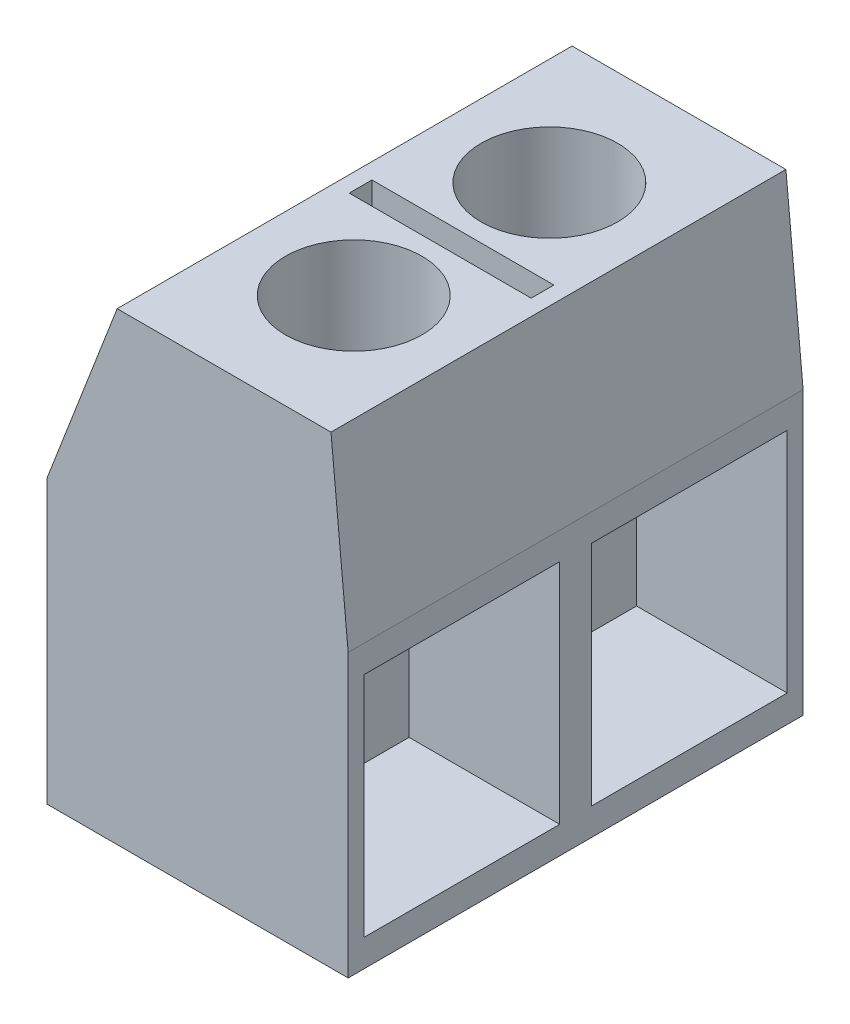
from build123d import *

# Parameters (mm, degrees)
BOSS_EXTRUDE2_DEPTH = 10
SKETCH3_W           = 4.3
SKETCH3_H           = 5
CUT_EXTRUDE3_DEPTH  = 4.3
SKETCH5_R           = 1.5
SKETCH5_W           = 4
SKETCH5_H           = 0.25
CUT_EXTRUDE4_DEPTH  = 5.3


with BuildPart() as part:
    # Sketch2 → Boss-Extrude2 (new body)
    with BuildSketch(Plane.XY):
        Polygon((-3.311102547, 0), (3.311102547, 0), (3.311102547, 6.2), (2.933626588, 10.202238361), (-1.766373412, 10.202238361), (-3.311102547, 6.2), align=None)
    extrude(amount=BOSS_EXTRUDE2_DEPTH)

    # Sketch3 → Cut-Extrude3 (cut)
    with BuildSketch(Plane(origin=(0, 0, 0), x_dir=(0, 0, -1), z_dir=(1, 0, 0))):
        with Locations((-2.5, 3.1)):
            Rectangle(SKETCH3_W, SKETCH3_H)
        with Locations((-7.5, 3.1)):
            Rectangle(SKETCH3_W, SKETCH3_H)
    extrude(amount=CUT_EXTRUDE3_DEPTH, mode=Mode.SUBTRACT)

    # Sketch5 → Cut-Extrude4 (cut)
    with BuildSketch(Plane(origin=(0, 10.202238361, 0), x_dir=(1, 0, 0), z_dir=(0, 1, 0))):
        with Locations((0.583626588, -7.15)):
            Circle(SKETCH5_R)
        with Locations((0.583626588, -5.125)):
            Rectangle(SKETCH5_W, SKETCH5_H)
        with Locations((0.583626588, -4.875)):
            Rectangle(SKETCH5_W, SKETCH5_H)
        with Locations((0.583626588, -2.85)):
            Circle(SKETCH5_R)
    extrude(amount=-CUT_EXTRUDE4_DEPTH, mode=Mode.SUBTRACT)


solid = part.part
